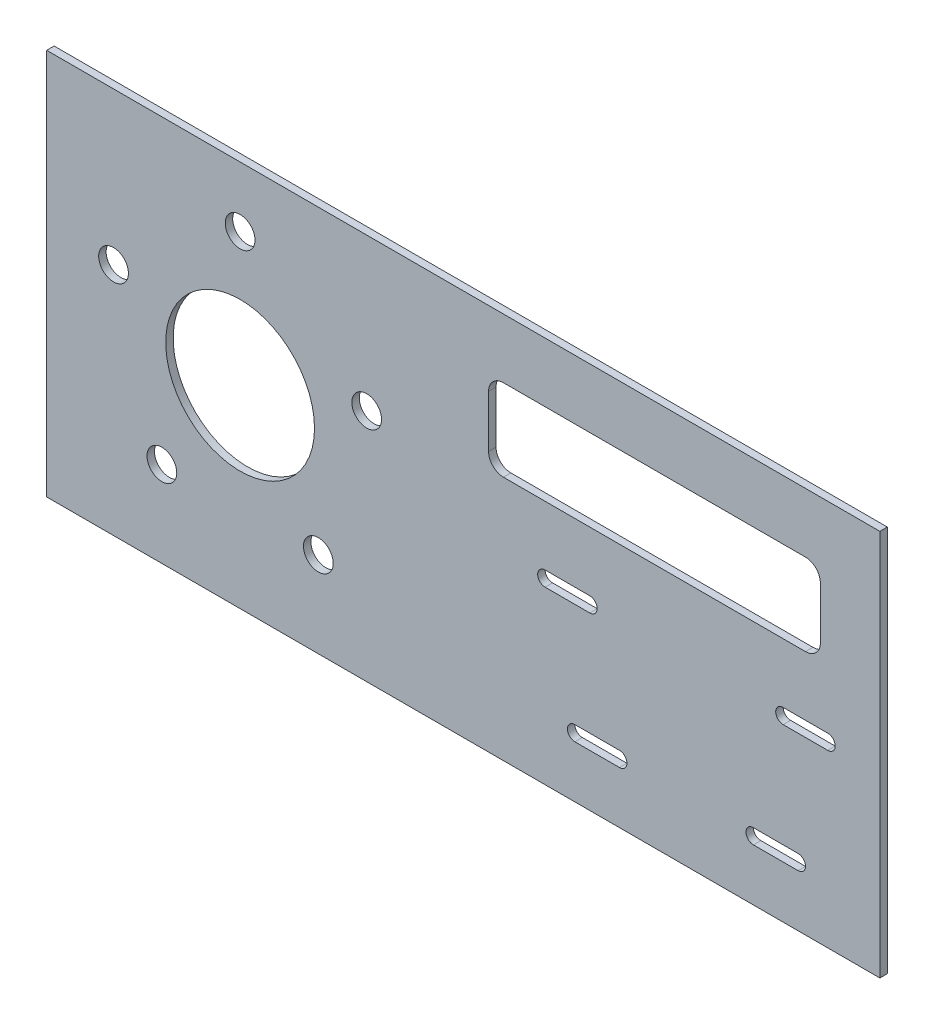
from build123d import *

# Parameters (mm, degrees)
SKETCH2_W           = 355.6
SKETCH2_H           = 165.1
SKETCH2_R           = 31.75
SKETCH2_R_2         = 6.35
BOSS_EXTRUDE1_DEPTH = 3.175
CUT_EXTRUDE1_DEPTH  = 4.175
CUT_EXTRUDE3_DEPTH  = 4.175


with BuildPart() as part:
    # Sketch2 → Boss-Extrude1 (new body)
    with BuildSketch(Plane.XY):
        with Locations((95.25, 0)):
            Rectangle(SKETCH2_W, SKETCH2_H)
        Circle(SKETCH2_R, mode=Mode.SUBTRACT)
        with Locations((-54.018973032, 17.551828308)):
            Circle(SKETCH2_R_2, mode=Mode.SUBTRACT)
        with Locations((0, 56.798909535)):
            Circle(SKETCH2_R_2, mode=Mode.SUBTRACT)
        with Locations((54.018973032, 17.551828308)):
            Circle(SKETCH2_R_2, mode=Mode.SUBTRACT)
        with Locations((33.385561371, -45.951283076)):
            Circle(SKETCH2_R_2, mode=Mode.SUBTRACT)
        with Locations((-33.385561371, -45.951283076)):
            Circle(SKETCH2_R_2, mode=Mode.SUBTRACT)
    extrude(amount=BOSS_EXTRUDE1_DEPTH)

    # Sketch3 → Cut-Extrude1 (cut, through all)
    with BuildSketch(Plane.XY.offset(3.175)):
        with BuildLine():
            Line((149.225, -9.525), (130.175, -9.525))
            ThreePointArc((130.175, -9.525), (127, -6.35), (130.175, -3.175))
            Line((130.175, -3.175), (149.225, -3.175))
            ThreePointArc((149.225, -3.175), (152.4, -6.35), (149.225, -9.525))
        make_face()
        with BuildLine():
            Line((250.825, -9.525), (231.775, -9.525))
            ThreePointArc((231.775, -9.525), (228.6, -6.35), (231.775, -3.175))
            Line((231.775, -3.175), (250.825, -3.175))
            ThreePointArc((250.825, -3.175), (254, -6.35), (250.825, -9.525))
        make_face()
        with BuildLine():
            Line((238.125, -60.325), (219.075, -60.325))
            ThreePointArc((219.075, -60.325), (215.9, -57.15), (219.075, -53.975))
            Line((219.075, -53.975), (238.125, -53.975))
            ThreePointArc((238.125, -53.975), (241.3, -57.15), (238.125, -60.325))
        make_face()
        with BuildLine():
            Line((142.875, -53.975), (161.925, -53.975))
            ThreePointArc((161.925, -53.975), (165.1, -57.15), (161.925, -60.325))
            Line((161.925, -60.325), (142.875, -60.325))
            ThreePointArc((142.875, -60.325), (139.7, -57.15), (142.875, -53.975))
        make_face()
    extrude(amount=-CUT_EXTRUDE1_DEPTH, mode=Mode.SUBTRACT)

    # Sketch4 → Cut-Extrude3 (cut, through all)
    with BuildSketch(Plane.XY.offset(3.175)):
        with BuildLine():
            Line((247.65, 28.575), (247.65, 50.8))
            ThreePointArc((247.65, 50.8), (245.790128061, 55.290128061), (241.3, 57.15))
            Line((241.3, 57.15), (112.395, 57.15))
            ThreePointArc((112.395, 57.15), (107.904871939, 55.290128061), (106.045, 50.8))
            Line((106.045, 50.8), (106.045, 28.575))
            ThreePointArc((106.045, 28.575), (107.904871939, 24.084871939), (112.395, 22.225))
            Line((112.395, 22.225), (241.3, 22.225))
            ThreePointArc((241.3, 22.225), (245.790128061, 24.084871939), (247.65, 28.575))
        make_face()
    extrude(amount=-CUT_EXTRUDE3_DEPTH, mode=Mode.SUBTRACT)


solid = part.part
